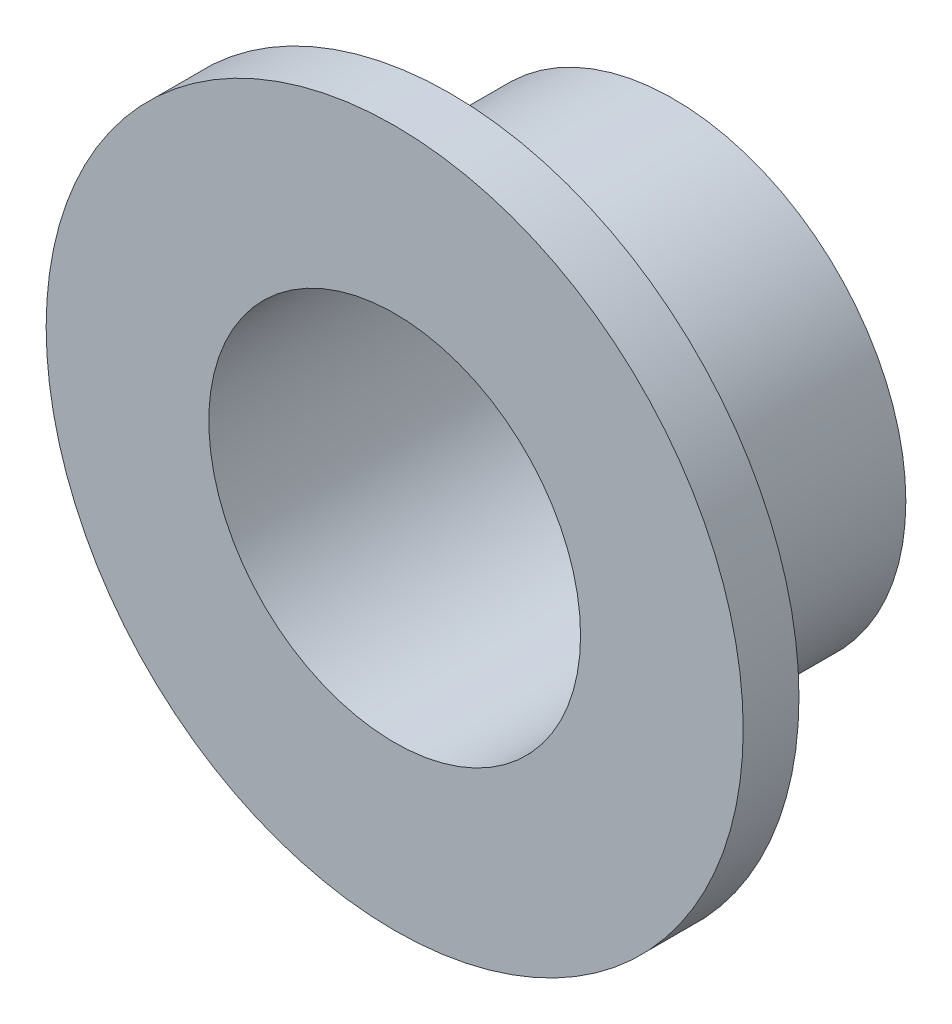
from build123d import *


with BuildPart() as part:
    # Sketch1 → Revolve1 (revolve)
    with BuildSketch(Plane(origin=(0, 0, 0), x_dir=(0, 0, -1), z_dir=(1, 0, 0))):
        Polygon((0, 4), (0, 7.5), (1.2, 7.5), (1.2, 5), (6, 5), (6, 4), align=None)
    revolve(axis=Axis((0, 0, 0), (0, 0, -1)))


solid = part.part
